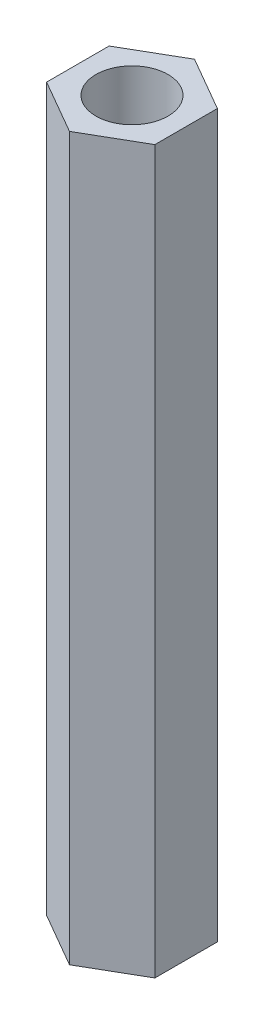
from build123d import *

# Parameters (mm, degrees)
SKETCH1_R           = 1
BOSS_EXTRUDE1_DEPTH = 20


with BuildPart() as part:
    # Sketch1 → Boss-Extrude1 (new body)
    with BuildSketch(Plane(origin=(0, 0, 0), x_dir=(1, 0, 0), z_dir=(0, 1, 0))):
        Polygon((0, -1.732050808), (1.5, -0.866025404), (1.5, 0.866025404), (0, 1.732050808), (-1.5, 0.866025404), (-1.5, -0.866025404), align=None)
        Circle(SKETCH1_R, mode=Mode.SUBTRACT)
    extrude(amount=BOSS_EXTRUDE1_DEPTH)


solid = part.part
